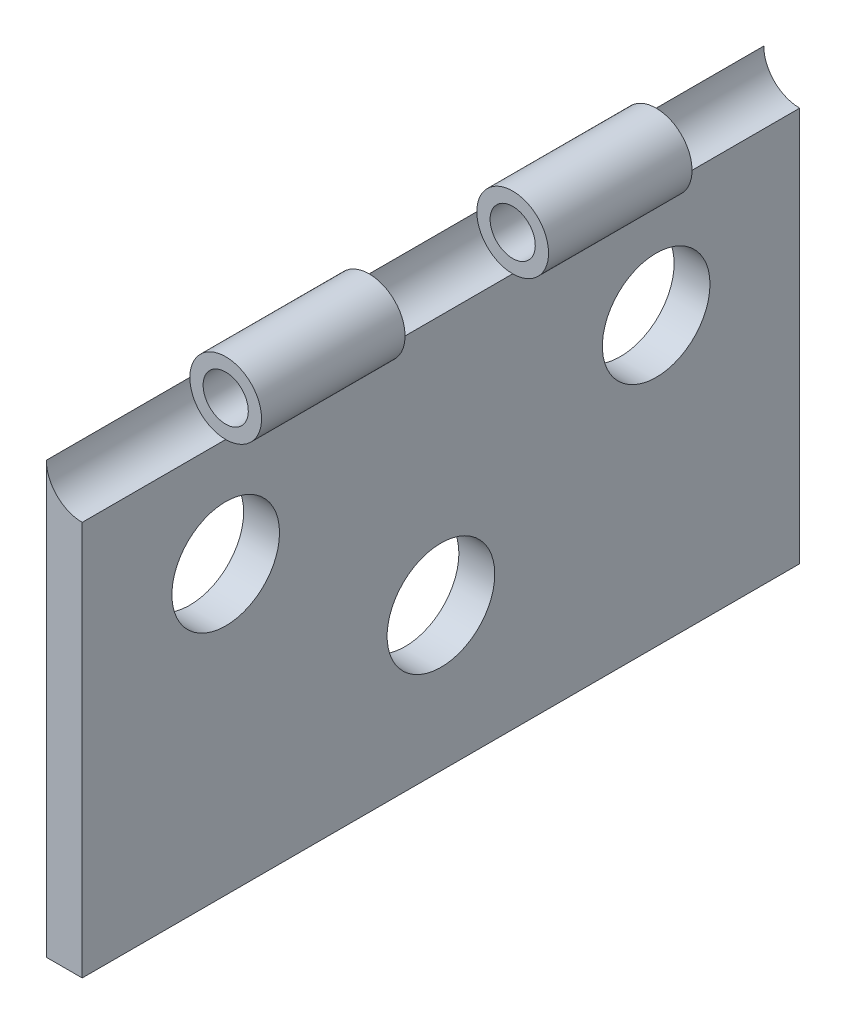
from build123d import *

# Parameters (mm, degrees)
SKETCH1_W           = 50
SKETCH1_H           = 30
SKETCH1_R           = 3.75
BOSS_EXTRUDE1_DEPTH = 2.5
BOSS_EXTRUDE2_START = -20
SKETCH3_R           = 2.5
BOSS_EXTRUDE2_DEPTH = 10
LPATTERN1_COUNT     = 2
LPATTERN1_PITCH     = 20
SKETCH5_R           = 1.575
CUT_EXTRUDE1_DEPTH  = 50
SKETCH6_R           = 2.5
CUT_EXTRUDE2_DEPTH  = 10
LPATTERN2_COUNT     = 3
LPATTERN2_PITCH     = 20
ESCALA1_SCALE       = 0.5


with BuildPart() as part:
    # Sketch1 → Boss-Extrude1 (new body)
    with BuildSketch(Plane(origin=(0, 0, 0), x_dir=(0, 0, -1), z_dir=(1, 0, 0))):
        with Locations((25, 15)):
            Rectangle(SKETCH1_W, SKETCH1_H)
        with Locations((40, 20)):
            Circle(SKETCH1_R, mode=Mode.SUBTRACT)
        with Locations((25, 10)):
            Circle(SKETCH1_R, mode=Mode.SUBTRACT)
        with Locations((10, 20)):
            Circle(SKETCH1_R, mode=Mode.SUBTRACT)
    extrude(amount=BOSS_EXTRUDE1_DEPTH)

    # Sketch3 → Boss-Extrude2 (add)
    with BuildSketch(Plane(origin=(0, 0, -50), x_dir=(-1, 0, 0), z_dir=(0, 0, -1)).offset(BOSS_EXTRUDE2_START)):
        with Locations((-2.5, 30)):
            Circle(SKETCH3_R)
    boss_extrude2 = extrude(amount=BOSS_EXTRUDE2_DEPTH)

    # LPattern1: Boss-Extrude2 ×2
    with Locations(*[(0, 0, i * LPATTERN1_PITCH) for i in range(1, LPATTERN1_COUNT)]):
        add(boss_extrude2)

    # Sketch5 → Cut-Extrude1 (cut)
    with BuildSketch(Plane(origin=(0, 0, -50), x_dir=(-1, 0, 0), z_dir=(0, 0, -1))):
        with Locations((-2.5, 30)):
            Circle(SKETCH5_R)
    extrude(amount=-CUT_EXTRUDE1_DEPTH, mode=Mode.SUBTRACT)

    # Sketch6 → Cut-Extrude2 (cut)
    with BuildSketch(Plane(origin=(0, 0, -50), x_dir=(-1, 0, 0), z_dir=(0, 0, -1))):
        with Locations((-2.5, 30)):
            Circle(SKETCH6_R)
    cut_extrude2 = extrude(amount=-CUT_EXTRUDE2_DEPTH, mode=Mode.SUBTRACT)

    # LPattern2: Cut-Extrude2 ×3
    with Locations(*[(0, 0, i * LPATTERN2_PITCH) for i in range(1, LPATTERN2_COUNT)]):
        add(cut_extrude2, mode=Mode.SUBTRACT)


with BuildPart() as part_1:
    # Escala1: scaled about (0, 0, 0)
    add(part.part.scale(ESCALA1_SCALE))


solid = part_1.part
